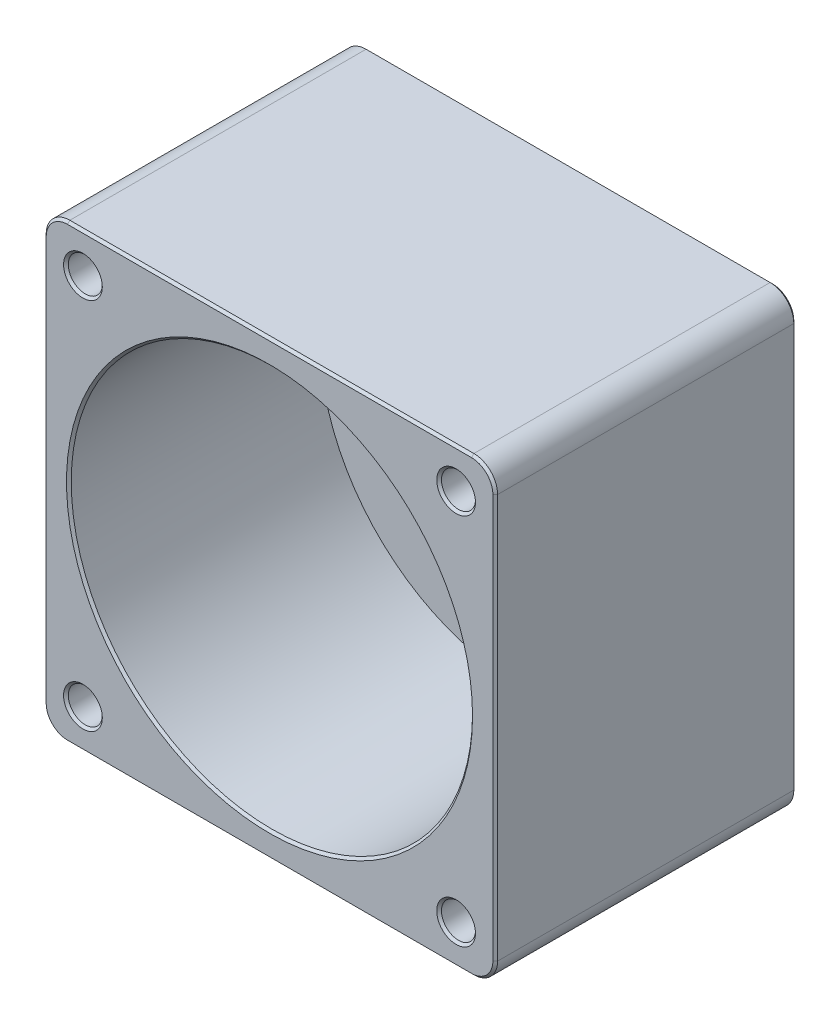
from build123d import *

# Parameters (mm, degrees)
SKETCH1_W           = 57.15
SKETCH1_H           = 57.15
SKETCH1_R           = 2.15265
SKETCH1_R_2         = 3.99923
BOSS_EXTRUDE1_DEPTH = 6.35
SKETCH1_3_W         = 57.15
SKETCH1_3_H         = 57.15
SKETCH1_3_R         = 2.15265
SKETCH1_3_R_2       = 25.4
BOSS_EXTRUDE2_DEPTH = 38.1
FILLET1_R           = 3
CHAMFER1_SIZE       = 0.3


with BuildPart() as part:
    # Sketch1 → Boss-Extrude1 (new body)
    with BuildSketch(Plane.XY):
        Rectangle(SKETCH1_W, SKETCH1_H)
        with Locations((-23.622, -23.622)):
            Circle(SKETCH1_R, mode=Mode.SUBTRACT)
        with Locations((23.622, -23.622)):
            Circle(SKETCH1_R, mode=Mode.SUBTRACT)
        with Locations((-23.622, 23.622)):
            Circle(SKETCH1_R, mode=Mode.SUBTRACT)
        with Locations((23.622, 23.622)):
            Circle(SKETCH1_R, mode=Mode.SUBTRACT)
        Circle(SKETCH1_R_2, mode=Mode.SUBTRACT)
    extrude(amount=BOSS_EXTRUDE1_DEPTH)

    # Sketch1_3 → Boss-Extrude2 (add)
    with BuildSketch(Plane.XY):
        Rectangle(SKETCH1_3_W, SKETCH1_3_H)
        with Locations((-23.622, -23.622)):
            Circle(SKETCH1_3_R, mode=Mode.SUBTRACT)
        Circle(SKETCH1_3_R_2, mode=Mode.SUBTRACT)
        with Locations((23.622, -23.622)):
            Circle(SKETCH1_3_R, mode=Mode.SUBTRACT)
        with Locations((-23.622, 23.622)):
            Circle(SKETCH1_3_R, mode=Mode.SUBTRACT)
        with Locations((23.622, 23.622)):
            Circle(SKETCH1_3_R, mode=Mode.SUBTRACT)
    extrude(amount=BOSS_EXTRUDE2_DEPTH)

    # Fillet1
    fillet1_edges = [part.edges().sort_by_distance(p)[0] for p in [
        (-28.575, 28.575, 19.05),
        (28.575, 28.575, 19.05),
        (28.575, -28.575, 19.05),
        (-28.575, -28.575, 19.05),
    ]]
    fillet(fillet1_edges, radius=FILLET1_R)

    # Chamfer1
    chamfer1_edges = [part.edges().sort_by_distance(p)[0] for p in [
        (-25.77465, -23.622, 0),
        (21.46935, -23.622, 0),
        (21.46935, 23.622, 0),
        (-25.77465, 23.622, 0),
        (-27.696320344, -27.696320344, 0),
        (0, -28.575, 0),
        (27.696320344, -27.696320344, 0),
        (28.575, 0, 0),
        (27.696320344, 27.696320344, 0),
        (0, 28.575, 0),
        (-27.696320344, 27.696320344, 0),
        (-28.575, 0, 0),
        (-3.99923, 0, 0),
        (27.696320344, 27.696320344, 38.1),
        (28.575, 0, 38.1),
        (27.696320344, -27.696320344, 38.1),
        (0, -28.575, 38.1),
        (-27.696320344, -27.696320344, 38.1),
        (-28.575, 0, 38.1),
        (-27.696320344, 27.696320344, 38.1),
        (0, 28.575, 38.1),
        (-25.77465, 23.622, 38.1),
        (21.46935, 23.622, 38.1),
        (21.46935, -23.622, 38.1),
        (-25.77465, -23.622, 38.1),
        (-25.4, 0, 38.1),
        (-3.99923, 0, 6.35),
    ]]
    chamfer(chamfer1_edges, length=CHAMFER1_SIZE)


solid = part.part
